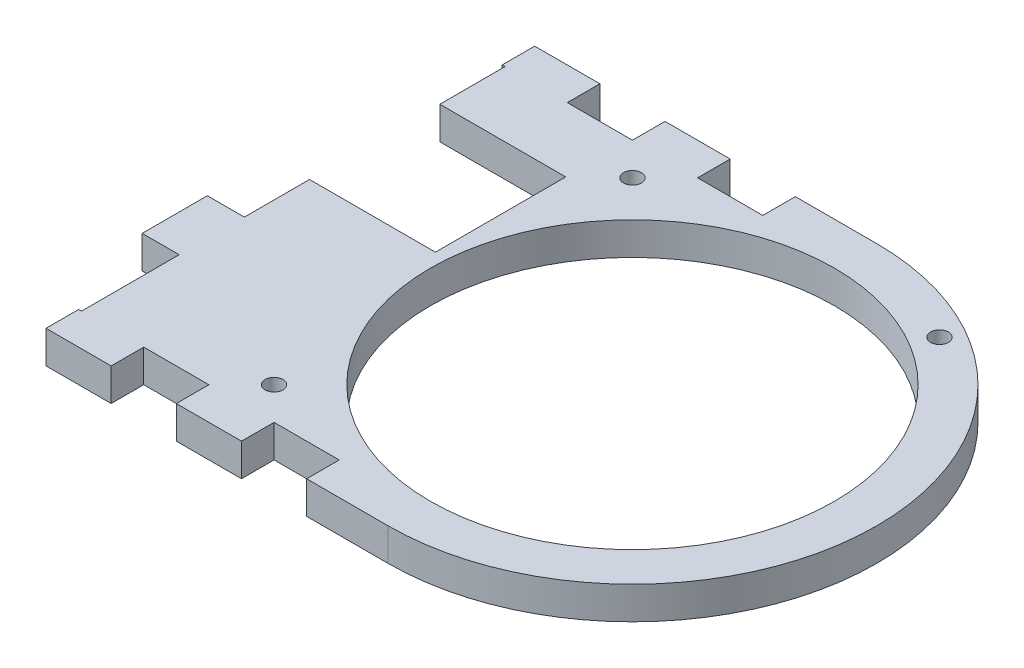
from build123d import *

# Parameters (mm, degrees)
SKETCH2_W           = 120.952956328
SKETCH2_H           = 6.35
BOSS_EXTRUDE1_DEPTH = 95.25
SKETCH3_R           = 39.37
CUT_EXTRUDE2_DEPTH  = 7.35
CUT_EXTRUDE3_DEPTH  = 7.35
SKETCH5_W           = 31.75
SKETCH5_H           = 25.4
CUT_EXTRUDE4_DEPTH  = 7.35
SKETCH6_W           = 12.7
SKETCH6_H           = 6.35
CUT_EXTRUDE5_DEPTH  = 7.35
LPATTERN1_COUNT     = 3
LPATTERN1_PITCH     = 25.4
SKETCH7_W           = 7.21259173
SKETCH7_H           = 12.7
SKETCH7_H_2         = 19.05
CUT_EXTRUDE6_DEPTH  = 7.35
SKETCH8_R           = 1.75
CUT_EXTRUDE7_DEPTH  = 7.35
SKETCH10_R          = 1.75
CUT_EXTRUDE9_DEPTH  = 7.35


with BuildPart() as part:
    # Sketch2 → Boss-Extrude1 (new body)
    with BuildSketch(Plane.XY):
        with Locations((98.782063621, 3.175)):
            Rectangle(SKETCH2_W, SKETCH2_H)
    extrude(amount=BOSS_EXTRUDE1_DEPTH)

    # Sketch3 → Cut-Extrude2 (cut, through all)
    with BuildSketch(Plane(origin=(0, 6.35, 0), x_dir=(1, 0, 0), z_dir=(0, 1, 0))):
        with Locations((111.633541785, -47.625)):
            Circle(SKETCH3_R)
    extrude(amount=-CUT_EXTRUDE2_DEPTH, mode=Mode.SUBTRACT)

    # Sketch4 → Cut-Extrude3 (cut, through all)
    with BuildSketch(Plane(origin=(0, 6.35, 0), x_dir=(1, 0, 0), z_dir=(0, 1, 0))):
        with BuildLine():
            Line((111.633541785, -95.25), (179.051442703, -95.25))
            Line((179.051442703, -95.25), (179.051442703, 0))
            Line((179.051442703, 0), (111.633541785, 0))
            ThreePointArc((111.633541785, 0), (159.258541785, -47.625), (111.633541785, -95.25))
        make_face()
    extrude(amount=-CUT_EXTRUDE3_DEPTH, mode=Mode.SUBTRACT)

    # Sketch5 → Cut-Extrude4 (cut, through all)
    with BuildSketch(Plane(origin=(0, 6.35, 0), x_dir=(1, 0, 0), z_dir=(0, 1, 0))):
        with Locations((54.180585457, -31.75)):
            Rectangle(SKETCH5_W, SKETCH5_H)
    extrude(amount=-CUT_EXTRUDE4_DEPTH, mode=Mode.SUBTRACT)

    # Sketch6 → Cut-Extrude5 (cut, through all)
    with BuildSketch(Plane(origin=(0, 6.35, 0), x_dir=(1, 0, 0), z_dir=(0, 1, 0))):
        with Locations((89.408541785, -3.175)):
            Rectangle(SKETCH6_W, SKETCH6_H)
        with Locations((89.408541785, -92.075)):
            Rectangle(SKETCH6_W, SKETCH6_H)
    cut_extrude5 = extrude(amount=-CUT_EXTRUDE5_DEPTH, mode=Mode.SUBTRACT)

    # LPattern1: Cut-Extrude5 ×3
    with Locations(*[(-i * LPATTERN1_PITCH, 0, 0) for i in range(1, LPATTERN1_COUNT)]):
        add(cut_extrude5, mode=Mode.SUBTRACT)

    # Sketch7 → Cut-Extrude6 (cut, through all)
    with BuildSketch(Plane(origin=(0, 6.35, 0), x_dir=(1, 0, 0), z_dir=(0, 1, 0))):
        with Locations((41.911881322, -12.7)):
            Rectangle(SKETCH7_W, SKETCH7_H)
        with Locations((41.911881322, -79.375)):
            Rectangle(SKETCH7_W, SKETCH7_H_2)
        with Locations((41.911881322, -50.8)):
            Rectangle(SKETCH7_W, SKETCH7_H)
    extrude(amount=-CUT_EXTRUDE6_DEPTH, mode=Mode.SUBTRACT)

    # Sketch8 → Cut-Extrude7 (cut, through all)
    with BuildSketch(Plane(origin=(0, 6.35, 0), x_dir=(1, 0, 0), z_dir=(0, 1, 0))):
        with Locations((76.708541785, -12.7)):
            Circle(SKETCH8_R)
        with Locations((76.708541785, -82.55)):
            Circle(SKETCH8_R)
    extrude(amount=-CUT_EXTRUDE7_DEPTH, mode=Mode.SUBTRACT)

    # Sketch10 → Cut-Extrude9 (cut, through all)
    with BuildSketch(Plane(origin=(0, 6.35, 0), x_dir=(1, 0, 0), z_dir=(0, 1, 0))):
        with Locations((133.541041785, -9.680096933)):
            Circle(SKETCH10_R)
    extrude(amount=-CUT_EXTRUDE9_DEPTH, mode=Mode.SUBTRACT)


solid = part.part
